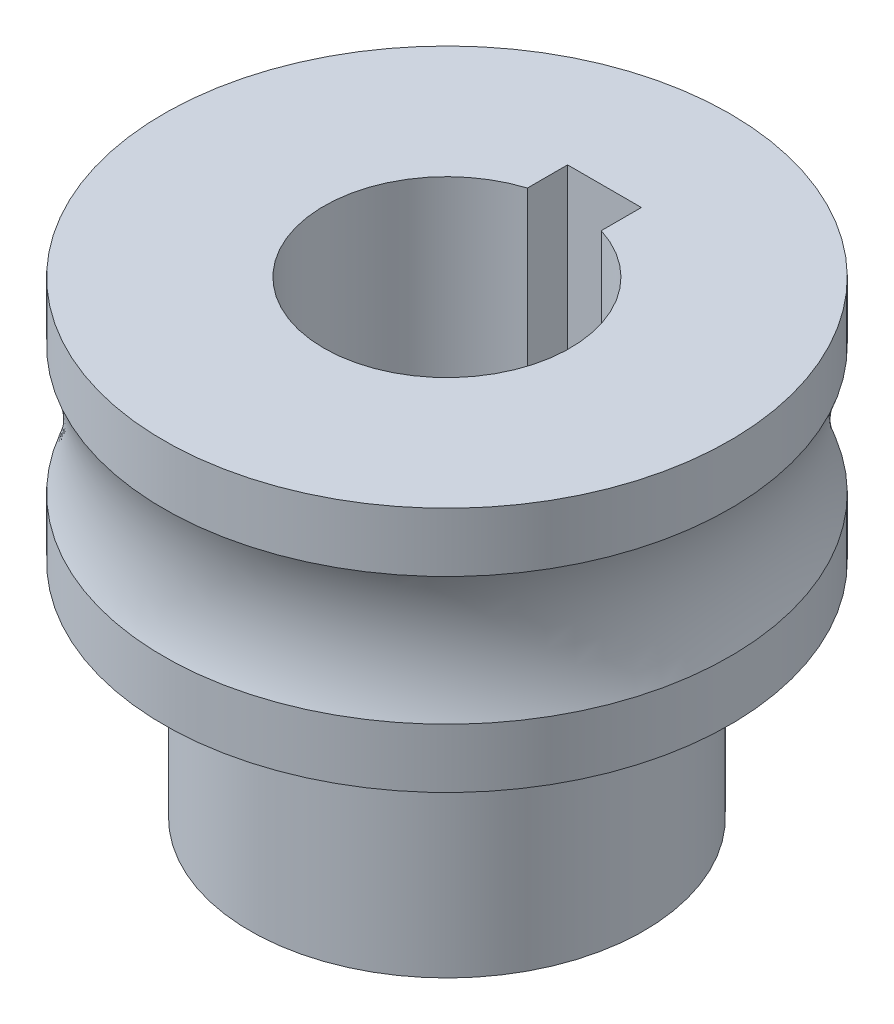
from build123d import *

# Parameters (mm, degrees)
ESQUISSE1_W             = 3
ESQUISSE1_H             = 2.8
ENL_V_MAT_EXTRU_1_DEPTH = 21
ESQUISSE2_R             = 8
ENL_V_MAT_EXTRU_2_DEPTH = 1


with BuildPart() as part:
    # Sketch1 → Revolve2 (revolve)
    with BuildSketch(Plane.XY):
        with BuildLine():
            Line((5, -15), (8, -15))
            Line((8, -15), (8, -5))
            Line((8, -5), (11.5, -5))
            Line((11.5, -5), (11.5, -2.598076211))
            ThreePointArc((11.5, -2.598076211), (11, 0), (11.5, 2.598076211))
            Line((11.5, 2.598076211), (11.5, 5))
            Line((11.5, 5), (5, 5))
            Line((5, 5), (5, -15))
        make_face()
    revolve(axis=Axis((0, -15, 0), (0, 1, 0)))

    # Esquisse1 → Enlèv. mat.-Extru.1 (cut, through all)
    with BuildSketch(Plane(origin=(0, 5, 0), x_dir=(1, 0, 0), z_dir=(0, 1, 0))):
        with Locations((0, 5)):
            Rectangle(ESQUISSE1_W, ESQUISSE1_H)
    extrude(amount=-ENL_V_MAT_EXTRU_1_DEPTH, mode=Mode.SUBTRACT)

    # Esquisse2 → Enlèv. mat.-Extru.2 (cut)
    with BuildSketch(Plane.XZ.offset(15)):
        Circle(ESQUISSE2_R)
    extrude(amount=-ENL_V_MAT_EXTRU_2_DEPTH, mode=Mode.SUBTRACT)


solid = part.part
